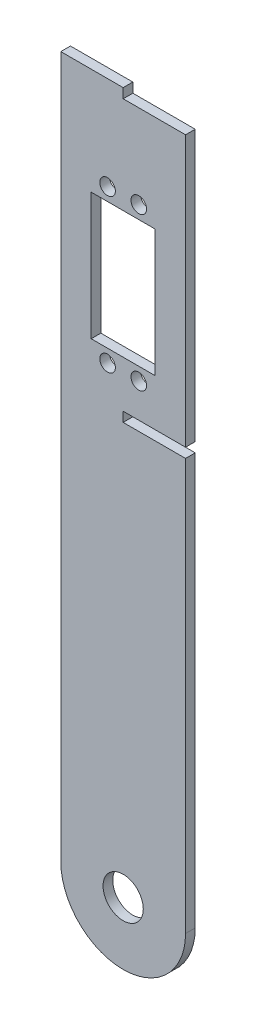
from build123d import *

# Parameters (mm, degrees)
SKETCH1_R           = 6.45
SKETCH1_R_2         = 2.5
SKETCH1_W           = 20.5
SKETCH1_H           = 40.7
BOSS_EXTRUDE1_DEPTH = 3.1
SKETCH2_W           = 20.093106281
SKETCH2_H           = 3.1
SKETCH2_W_2         = 20
CUT_EXTRUDE1_DEPTH  = 4.1


with BuildPart() as part:
    # Sketch1 → Boss-Extrude1 (new body)
    with BuildSketch(Plane.XY):
        with BuildLine():
            Line((-20, 0), (-20, 224.85))
            Line((-20, 224.85), (20, 224.85))
            Line((20, 224.85), (20, 0))
            ThreePointArc((20, 0), (0, -20), (-20, 0))
        make_face()
        Circle(SKETCH1_R, mode=Mode.SUBTRACT)
        with Locations((5, 145.85)):
            Circle(SKETCH1_R_2, mode=Mode.SUBTRACT)
        with Locations((-5, 145.85)):
            Circle(SKETCH1_R_2, mode=Mode.SUBTRACT)
        with Locations((-5, 194.85)):
            Circle(SKETCH1_R_2, mode=Mode.SUBTRACT)
        with Locations((5, 194.85)):
            Circle(SKETCH1_R_2, mode=Mode.SUBTRACT)
        with Locations((0, 170.35)):
            Rectangle(SKETCH1_W, SKETCH1_H, mode=Mode.SUBTRACT)
    extrude(amount=BOSS_EXTRUDE1_DEPTH)

    # Sketch2 → Cut-Extrude1 (cut, through all)
    with BuildSketch(Plane.XY.offset(3.1)):
        with Locations((10.046553141, 223.3)):
            Rectangle(SKETCH2_W, SKETCH2_H)
        with Locations((10, 133.45)):
            Rectangle(SKETCH2_W_2, SKETCH2_H)
    extrude(amount=-CUT_EXTRUDE1_DEPTH, mode=Mode.SUBTRACT)


solid = part.part
